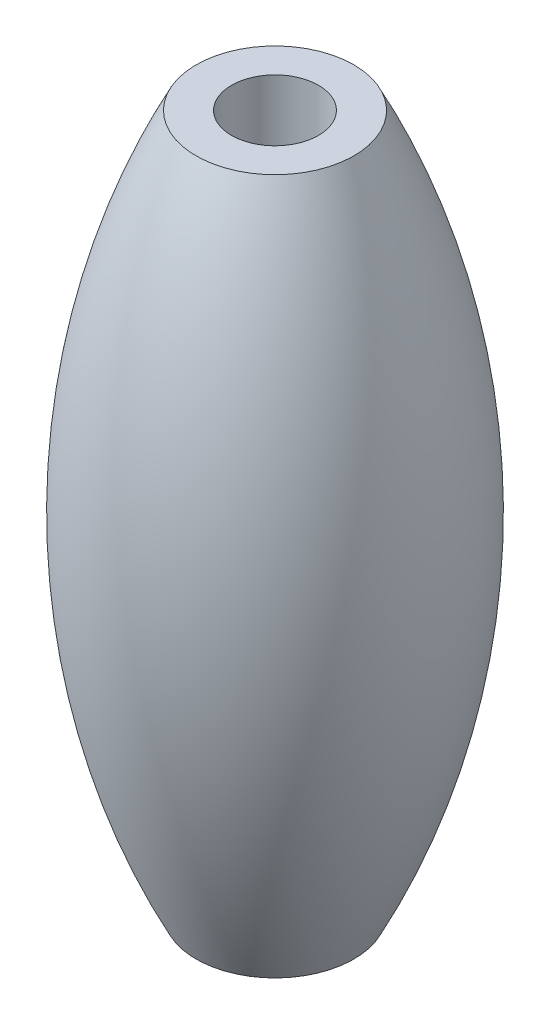
from build123d import *

# Parameters (mm, degrees)
F_3_0MM_DOWEL_HOLE1_D = 3.5


with BuildPart() as part:
    # Sketch1 → Revolve1 (revolve)
    with BuildSketch(Plane.XY):
        with BuildLine():
            Line((0, -14), (0, 14))
            Line((0, 14), (3.175, 14))
            ThreePointArc((3.175, 14), (6.5, 0), (3.175, -14))
            Line((3.175, -14), (0, -14))
        make_face()
    revolve(axis=Axis((0, -14, 0), (0, 1, 0)))

    # Ø3.0mm Dowel Hole1 (through all)
    with Locations(Plane(origin=(0, 14, 0), x_dir=(1, 0, 0), z_dir=(0, 1, 0))):
        with Locations((0, 0)):
            Hole(F_3_0MM_DOWEL_HOLE1_D / 2)


solid = part.part
